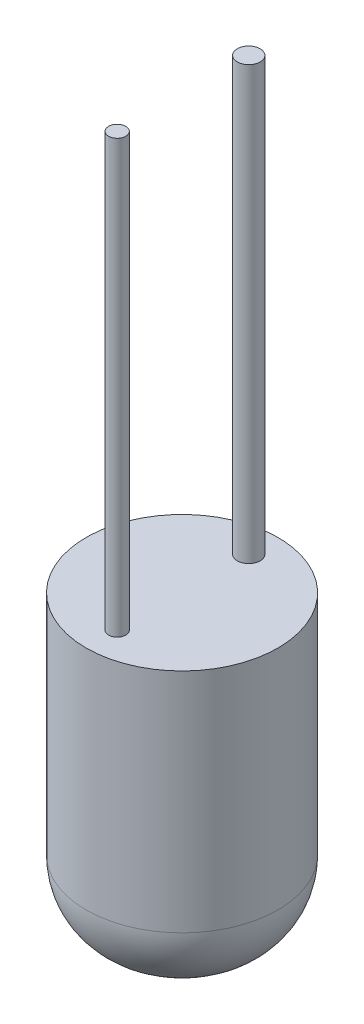
from build123d import *

# Parameters (mm, degrees)
SKETCH1_R           = 2.254320316
BOSS_EXTRUDE1_DEPTH = 7.112
SKETCH2_R           = 0.268830558
SKETCH2_R_2         = 0.202182998
BOSS_EXTRUDE2_DEPTH = 10.16
FILLET4_R           = 1.778


with BuildPart() as part:
    # Sketch1 → Boss-Extrude1 (new body)
    with BuildSketch(Plane(origin=(0, 0, 0), x_dir=(1, 0, 0), z_dir=(0, 1, 0))):
        Circle(SKETCH1_R)
    extrude(amount=BOSS_EXTRUDE1_DEPTH)

    # Sketch2 → Boss-Extrude2 (add)
    with BuildSketch(Plane(origin=(0, 7.112, 0), x_dir=(1, 0, 0), z_dir=(0, 1, 0))):
        with Locations((0, 1.567947129)):
            Circle(SKETCH2_R)
        with Locations((0, -1.52494477)):
            Circle(SKETCH2_R_2)
    extrude(amount=BOSS_EXTRUDE2_DEPTH)

    # Fillet4
    fillet4_edges = [part.edges().sort_by_distance(p)[0] for p in [
        (-2.254320316, 0, 0),
    ]]
    fillet(fillet4_edges, radius=FILLET4_R)


solid = part.part
